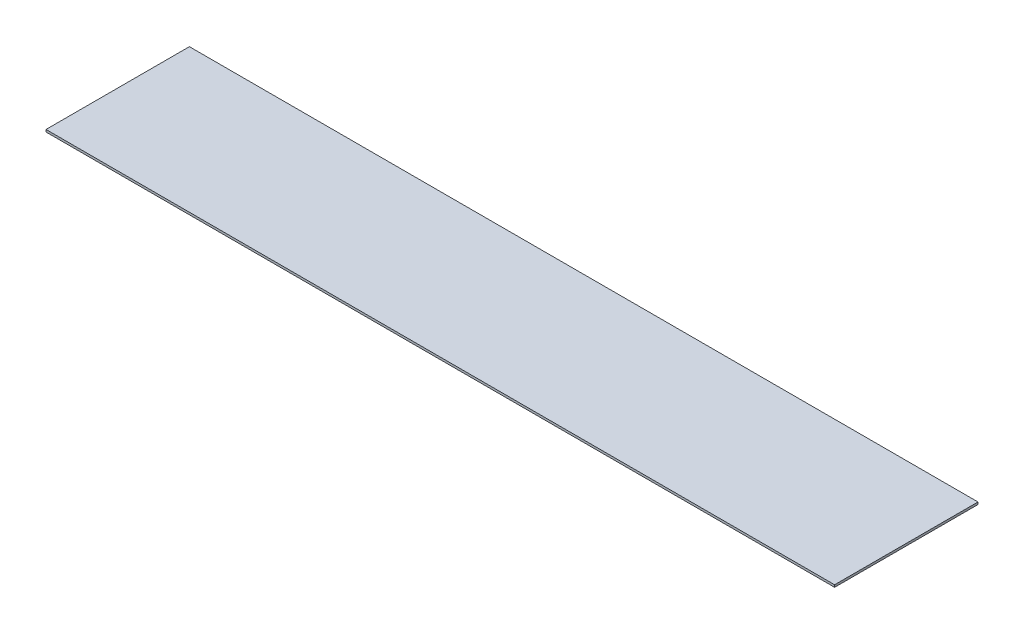
from build123d import *

# Parameters (mm, degrees)
SKETCH1_W           = 558.8
SKETCH1_H           = 101.6
BOSS_EXTRUDE1_DEPTH = 1.5875


with BuildPart() as part:
    # Sketch1 → Boss-Extrude1 (new body)
    with BuildSketch(Plane(origin=(0, 0, 0), x_dir=(1, 0, 0), z_dir=(0, 1, 0))):
        with Locations((279.4, 50.8)):
            Rectangle(SKETCH1_W, SKETCH1_H)
    extrude(amount=BOSS_EXTRUDE1_DEPTH)


solid = part.part
